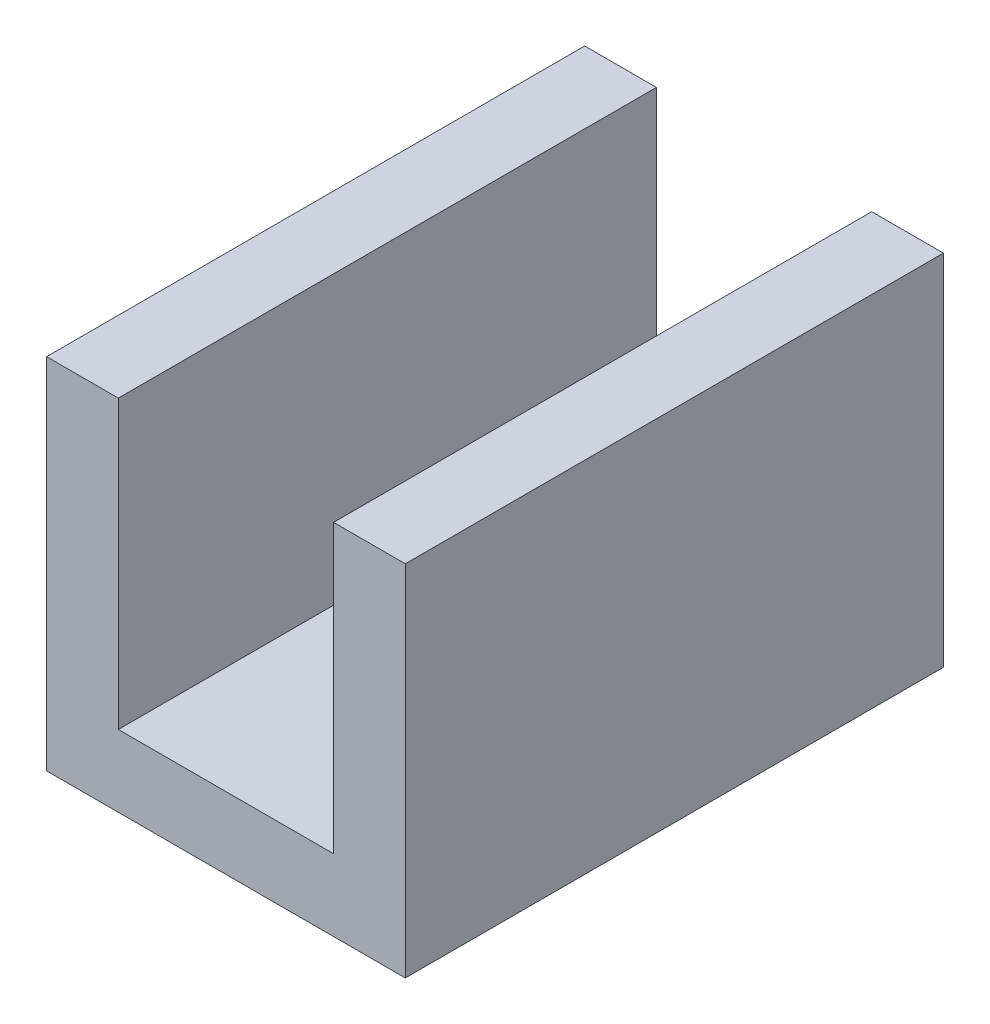
from build123d import *

# Parameters (mm, degrees)
BOSS_EXTRUDE1_DEPTH = 381


with BuildPart() as part:
    # Sketch1 → Boss-Extrude1 (new body)
    with BuildSketch(Plane.XY):
        Polygon((0, 0), (0, 254), (50.8, 254), (50.8, 50.8), (203.2, 50.8), (203.2, 254), (254, 254), (254, 0), align=None)
    extrude(amount=-BOSS_EXTRUDE1_DEPTH)


solid = part.part
